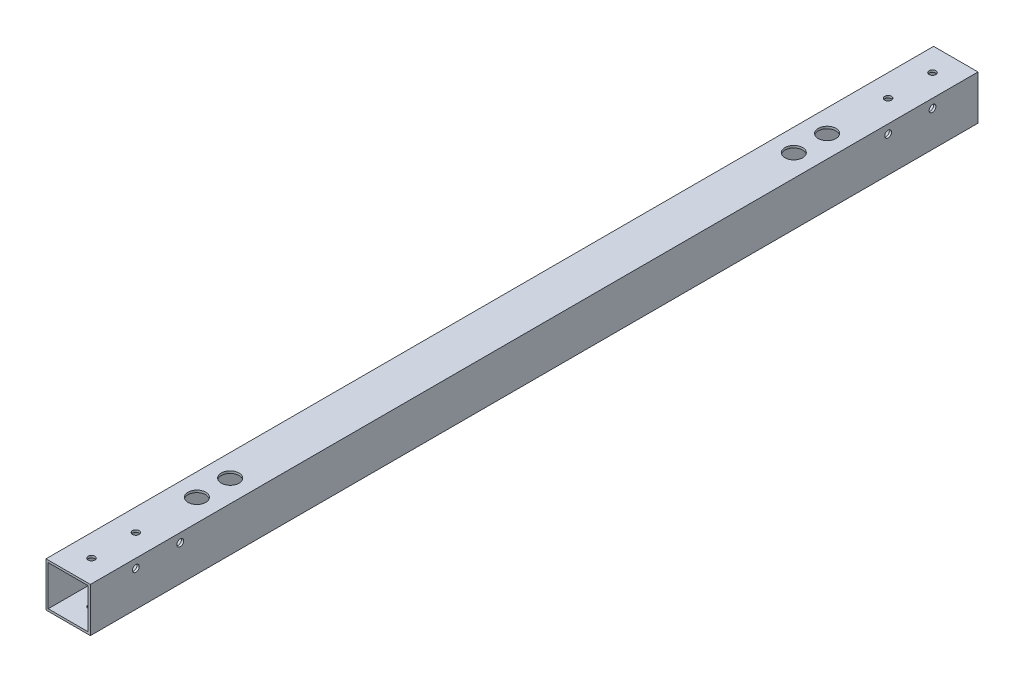
from build123d import *

# Parameters (mm, degrees)
SKETCH_1_W               = 20
SKETCH_1_H               = 20
EXTRUDE_1_DEPTH          = 200
SKETCH_2_W               = 18
SKETCH_2_H               = 18
CUT_EXTRUDE_1_DEPTH      = 201
CUT_EXTRUDE_1_DEPTH_BACK = 201
CUT_EXTRUDE_START        = -21
SKETCH_3_R               = 1.525
CUT_EXTRUDE_2_DEPTH      = 22
SKETCH_4_R               = 1.525
CUT_EXTRUDE_3_DEPTH      = 22
SKETCH_5_R               = 2.025
CUT_EXTRUDE_4_DEPTH      = 22
SKETCH_8_R               = 4
CUT_EXTRUDE_5_DEPTH      = 3


with BuildPart() as part:
    # 草图1 → 凸台-拉伸1 (new body, symmetric)
    with BuildSketch(Plane.XY):
        Rectangle(SKETCH_1_W, SKETCH_1_H)
    extrude(amount=EXTRUDE_1_DEPTH, both=True)

    # 草图2 → 切除-拉伸1 (cut, two sides)
    with BuildSketch(Plane.XY) as cut_extrude_1_sk:
        Rectangle(SKETCH_2_W, SKETCH_2_H)
    extrude(amount=CUT_EXTRUDE_1_DEPTH, mode=Mode.SUBTRACT)
    extrude(cut_extrude_1_sk.sketch, amount=-CUT_EXTRUDE_1_DEPTH_BACK, mode=Mode.SUBTRACT)

    # 草图3 → 切除-拉伸2 (cut)
    with BuildSketch(Plane(origin=(0, 10, 0), x_dir=(1, 0, 0), z_dir=(0, 1, 0)).offset(CUT_EXTRUDE_START)):
        with Locations((0, -189.5)):
            Circle(SKETCH_3_R)
        with Locations((0, -169.5)):
            Circle(SKETCH_3_R)
    cut_extrude_2 = extrude(amount=CUT_EXTRUDE_2_DEPTH, mode=Mode.SUBTRACT)

    # 镜向1: 切除-拉伸2 across plane
    add(cut_extrude_2.mirror(Plane.XY), mode=Mode.SUBTRACT)

    # 草图4 → 切除-拉伸3 (cut)
    with BuildSketch(Plane(origin=(10, 0, 0), x_dir=(0, 0, -1), z_dir=(1, 0, 0)).offset(CUT_EXTRUDE_START)):
        with Locations((-179.5, 6)):
            Circle(SKETCH_4_R)
        with Locations((-159.5, 6)):
            Circle(SKETCH_4_R)
    cut_extrude_3 = extrude(amount=CUT_EXTRUDE_3_DEPTH, mode=Mode.SUBTRACT)

    # 草图5 → 切除-拉伸4 (cut)
    with BuildSketch(Plane.XZ.offset(10).offset(CUT_EXTRUDE_START)):
        with Locations((0, 142)):
            Circle(SKETCH_5_R)
        with Locations((0, 127)):
            Circle(SKETCH_5_R)
    cut_extrude_4 = extrude(amount=CUT_EXTRUDE_4_DEPTH, mode=Mode.SUBTRACT)

    # 草图8 → 切除-拉伸5 (cut)
    with BuildSketch(Plane(origin=(0, 10, 0), x_dir=(1, 0, 0), z_dir=(0, 1, 0))):
        with Locations((0, -127)):
            Circle(SKETCH_8_R)
        with Locations((0, -142)):
            Circle(SKETCH_8_R)
    cut_extrude_5 = extrude(amount=-CUT_EXTRUDE_5_DEPTH, mode=Mode.SUBTRACT)

    # 镜向2: 切除-拉伸4, 切除-拉伸5 across plane
    add(cut_extrude_4.mirror(Plane.XY), mode=Mode.SUBTRACT)
    add(cut_extrude_5.mirror(Plane.XY), mode=Mode.SUBTRACT)

    # 镜向3: 切除-拉伸3 across plane
    add(cut_extrude_3.mirror(Plane.XY), mode=Mode.SUBTRACT)


solid = part.part
